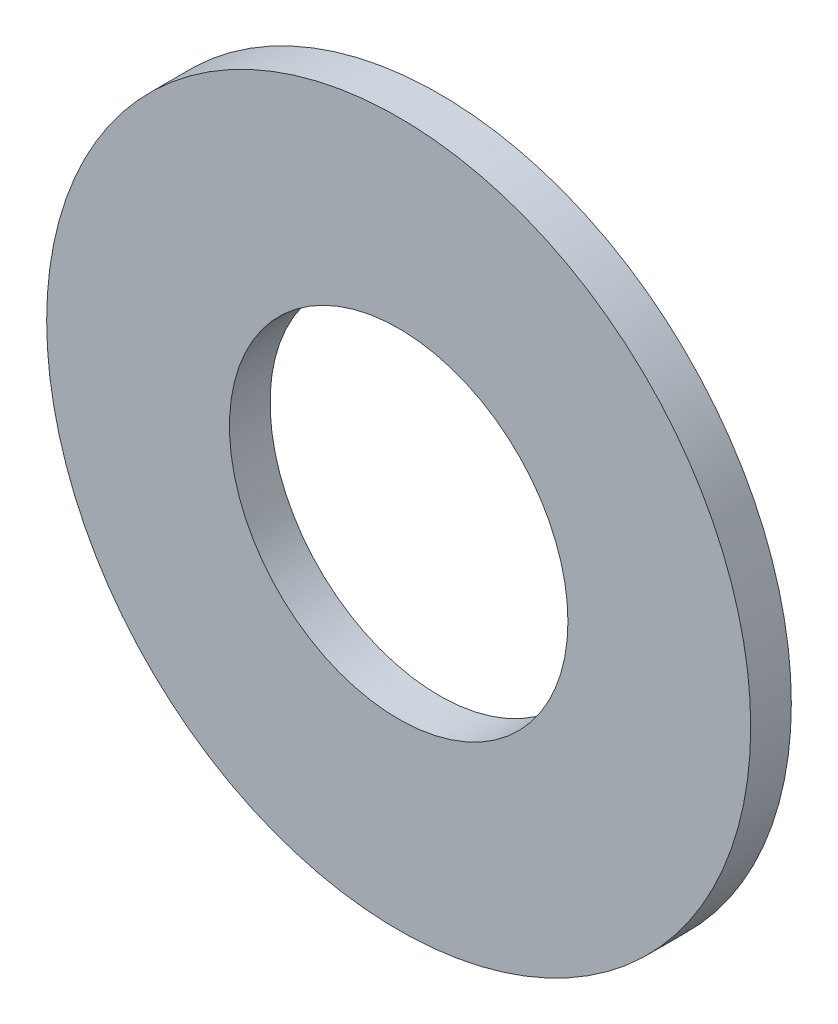
from build123d import *

# Parameters (mm, degrees)
SKETCH1_R           = 26
SKETCH1_R_2         = 12.5
BOSS_EXTRUDE1_DEPTH = 3


with BuildPart() as part:
    # Sketch1 → Boss-Extrude1 (new body)
    with BuildSketch(Plane.XY):
        Circle(SKETCH1_R)
        Circle(SKETCH1_R_2, mode=Mode.SUBTRACT)
    extrude(amount=BOSS_EXTRUDE1_DEPTH)


solid = part.part
